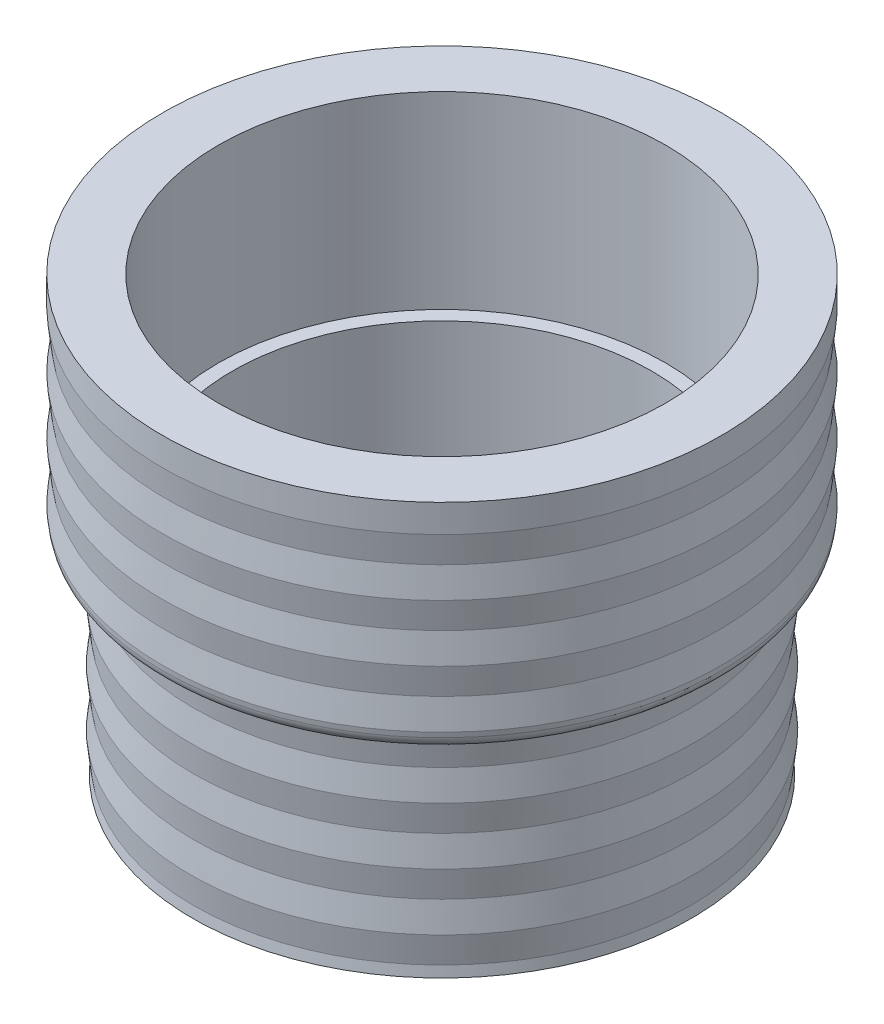
from build123d import *

# Parameters (mm, degrees)
LPATTERN1_COUNT = 6
LPATTERN1_PITCH = 6.477
FILLET1_R       = 1.5875


with BuildPart() as part:
    # Sketch2 → Revolve1 (revolve)
    with BuildSketch(Plane.XY):
        Polygon((25.4, 49.2125), (31.75, 49.2125), (31.75, 24.60625), (28.575, 24.60625), (28.575, 0), (22.225, 0), (22.225, 6.35), (23.8125, 6.35), (23.8125, 27.78125), (25.4, 27.78125), align=None)
    revolve(axis=Axis((0, -40.656569806, 0), (0, 1, 0)))

    # Sketch3 → Cut-Revolve1 (revolve, cut)
    with BuildSketch(Plane.XY):
        Polygon((31.75, 46.0375), (31.369, 42.799), (31.75, 39.5605), align=None)
        Polygon((28.575, 23.84425), (28.575, 17.36725), (28.194, 20.60575), align=None)
    cut_revolve1 = revolve(axis=Axis((0, -40.656569806, 0), (0, 1, 0)), mode=Mode.SUBTRACT)

    # LPattern1: Cut-Revolve1 ×6
    with Locations(*[(0, -i * LPATTERN1_PITCH, 0) for i in range(1, LPATTERN1_COUNT)]):
        add(cut_revolve1, mode=Mode.SUBTRACT)

    # Fillet1
    fillet1_edges = [part.edges().sort_by_distance(p)[0] for p in [
        (-31.514676471, 24.60625, 0),
    ]]
    fillet(fillet1_edges, radius=FILLET1_R)


solid = part.part
